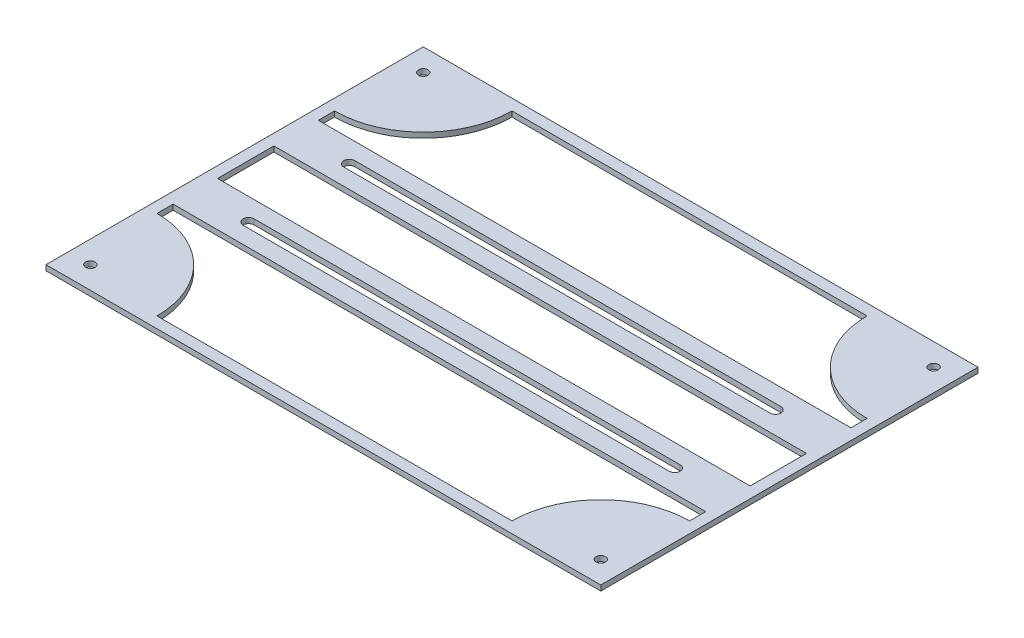
from build123d import *

# Parameters (mm, degrees)
SKETCH1_W             = 158.75
SKETCH1_H             = 107.95
SKETCH1_W_2           = 152.4
SKETCH1_H_2           = 16.134929366
BOSS_EXTRUDE1_DEPTH   = 1.524
CUT_EXTRUDE1_DEPTH    = 2.524
F_6_32_TAPPED_HOLE1_D = 2.7051
F_6_32_TAPPED_HOLE2_D = 2.7051


with BuildPart() as part:
    # Sketch1 → Boss-Extrude1 (new body)
    with BuildSketch(Plane(origin=(0, 0, 0), x_dir=(1, 0, 0), z_dir=(0, 1, 0))):
        Rectangle(SKETCH1_W, SKETCH1_H)
        with BuildLine():
            Line((-76.2, -25.4), (-76.2, -20.767464683))
            Line((-76.2, -20.767464683), (76.2, -20.767464683))
            Line((76.2, -20.767464683), (76.2, -25.4))
            ThreePointArc((76.2, -25.4), (58.239487758, -32.839487758), (50.8, -50.8))
            Line((50.8, -50.8), (-50.8, -50.8))
            ThreePointArc((-50.8, -50.8), (-58.239487758, -32.839487758), (-76.2, -25.4))
        make_face(mode=Mode.SUBTRACT)
        Rectangle(SKETCH1_W_2, SKETCH1_H_2, mode=Mode.SUBTRACT)
        with BuildLine():
            Line((76.2, 20.767464683), (-76.2, 20.767464683))
            Line((-76.2, 20.767464683), (-76.2, 25.4))
            ThreePointArc((-76.2, 25.4), (-58.239487758, 32.839487758), (-50.8, 50.8))
            Line((-50.8, 50.8), (50.8, 50.8))
            ThreePointArc((50.8, 50.8), (58.239487758, 32.839487758), (76.2, 25.4))
            Line((76.2, 25.4), (76.2, 20.767464683))
        make_face(mode=Mode.SUBTRACT)
    extrude(amount=BOSS_EXTRUDE1_DEPTH)

    # Sketch3 → Cut-Extrude1 (cut, through all)
    with BuildSketch(Plane(origin=(0, 1.524, 0), x_dir=(1, 0, 0), z_dir=(0, 1, 0))):
        with BuildLine():
            Line((-60.96, 16.004964683), (60.96, 16.004964683))
            ThreePointArc((60.96, 16.004964683), (62.5475, 14.417464683), (60.96, 12.829964683))
            Line((60.96, 12.829964683), (-60.96, 12.829964683))
            ThreePointArc((-60.96, 12.829964683), (-62.5475, 14.417464683), (-60.96, 16.004964683))
        make_face()
        with BuildLine():
            Line((-60.96, -16.004964683), (60.96, -16.004964683))
            ThreePointArc((60.96, -16.004964683), (62.5475, -14.417464683), (60.96, -12.829964683))
            Line((60.96, -12.829964683), (-60.96, -12.829964683))
            ThreePointArc((-60.96, -12.829964683), (-62.5475, -14.417464683), (-60.96, -16.004964683))
        make_face()
    extrude(amount=-CUT_EXTRUDE1_DEPTH, mode=Mode.SUBTRACT)

    # #6-32 Tapped Hole1 (through all)
    with Locations(Plane(origin=(0, 7.8105, 0), x_dir=(-1, 0, 0), z_dir=(0, 1, 0))):
        with Locations((73.025, -47.625), (73.025, 47.625), (-73.025, 47.625), (-73.025, -47.625)):
            Hole(F_6_32_TAPPED_HOLE1_D / 2)

    # #6-32 Tapped Hole2 (through all)
    with Locations(Plane(origin=(0, 1.524, 0), x_dir=(-1, 0, 0), z_dir=(0, 1, 0))):
        with Locations((73.025, -47.625), (73.025, 47.625), (-73.025, 47.625), (-73.025, -47.625)):
            Hole(F_6_32_TAPPED_HOLE2_D / 2)


solid = part.part
